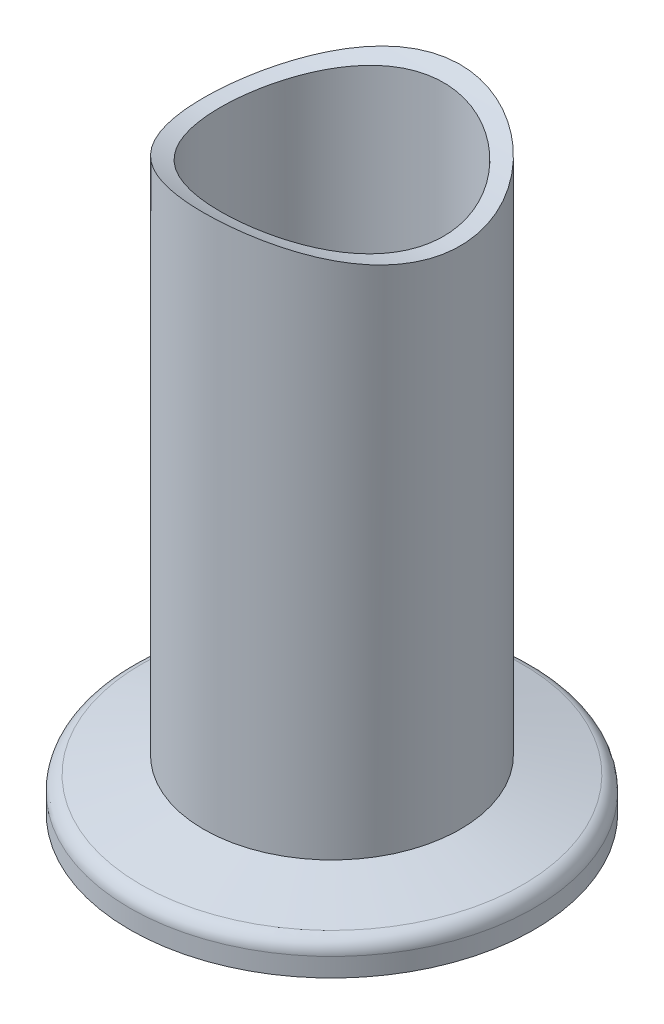
from build123d import *

# Parameters (mm, degrees)
SKETCH2_R               = 29.75
CUT_EXTRUDE2_DEPTH      = 21
CUT_EXTRUDE2_DEPTH_BACK = 21


with BuildPart() as part:
    # Sketch1 → Revolve1 (revolve)
    with BuildSketch(Plane(origin=(0, 0, 0), x_dir=(-1, 0, 0), z_dir=(0, 0, -1))):
        with BuildLine():
            Line((-12.7, 4.956029105), (-18.888228568, 3.297898257))
            ThreePointArc((-18.888228568, 3.297898257), (-19.69003001, 2.762151662), (-20, 1.849009518))
            Line((-20, 1.849009518), (-20, 0))
            Line((-20, 0), (-11.85, 0))
            Line((-11.85, 0), (-11.85, 2.5))
            Line((-11.85, 2.5), (-11.05, 2.5))
            Line((-11.05, 2.5), (-11.05, 70))
            Line((-11.05, 70), (-12.7, 70))
            Line((-12.7, 70), (-12.7, 4.956029105))
        make_face()
    revolve(axis=Axis((0, 0, 0), (0, 1, 0)))

    # Sketch2 → Cut-Extrude2 (cut, two sides)
    with BuildSketch(Plane(origin=(0, 0, 0), x_dir=(0, 0, -1), z_dir=(1, 0, 0))) as cut_extrude2_sk:
        with Locations((0, 84.706029105)):
            Circle(SKETCH2_R)
    extrude(amount=CUT_EXTRUDE2_DEPTH, mode=Mode.SUBTRACT)
    extrude(cut_extrude2_sk.sketch, amount=-CUT_EXTRUDE2_DEPTH_BACK, mode=Mode.SUBTRACT)


solid = part.part
